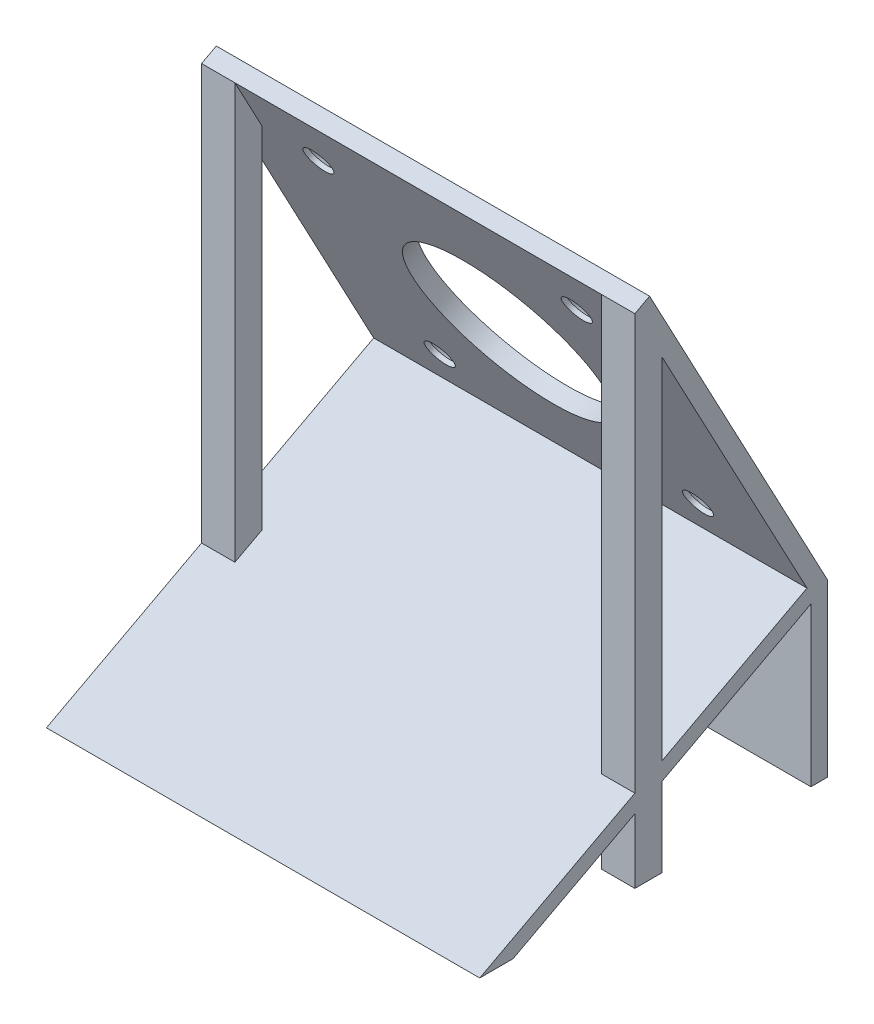
from build123d import *

# Parameters (mm, degrees)
SKETCH1_W                                           = 52
SKETCH1_H                                           = 100
BOSS_EXTRUDE1_DEPTH                                 = 5
BOSS_EXTRUDE3_DEPTH                                 = 2.5
SKETCH7_R                                           = 2.25
BOSS_EXTRUDE4_DEPTH                                 = 2.5
FILLET2_R                                           = 0.25
SKETCH9_W                                           = 52
SKETCH9_H                                           = 2
BOSS_EXTRUDE5_DEPTH                                 = 50
BOSS_EXTRUDE7_DEPTH                                 = 52
CUT_EXTRUDE3_DEPTH                                  = 52
CUT_EXTRUDE4_DEPTH                                  = 2.5
BOSS_EXTRUDE8_DEPTH                                 = 52
BOSS_EXTRUDE9_DEPTH                                 = 4
LPATTERN1_COUNT                                     = 2
LPATTERN1_PITCH                                     = 48
SKETCH18_R                                          = 11.5
CUT_EXTRUDE5_DEPTH                                  = 2
CSK_FOR_M3_COUNTERSUNK_FLAT_HEAD_SCREW1_D           = 3.4
CSK_FOR_M3_COUNTERSUNK_FLAT_HEAD_SCREW1_DEPTH       = 5
CSK_FOR_M3_COUNTERSUNK_FLAT_HEAD_SCREW1_CSINK_D     = 6.3
CSK_FOR_M3_COUNTERSUNK_FLAT_HEAD_SCREW1_CSINK_ANGLE = 90
CSK_FOR_M3_COUNTERSUNK_FLAT_HEAD_SCREW1_TIP         = 1.021463052
BOSS_EXTRUDE10_DEPTH                                = 5
SKETCH23_R                                          = 1.75
CUT_EXTRUDE6_DEPTH                                  = 5
SKETCH24_W                                          = 6.6
SKETCH24_H                                          = 5.6
CUT_EXTRUDE7_DEPTH                                  = 2.5
SKETCH25_W                                          = 75
SKETCH25_H                                          = 5
SKETCH25_W_2                                        = 28.673992526
SKETCH25_H_2                                        = 8.232083525
CUT_EXTRUDE8_DEPTH                                  = 88


with BuildPart() as part:
    # Sketch1 → Boss-Extrude1 (new body)
    with BuildSketch(Plane(origin=(0, 0, 0), x_dir=(1, 0, 0), z_dir=(0, 1, 0))):
        Rectangle(SKETCH1_W, SKETCH1_H)
    extrude(amount=BOSS_EXTRUDE1_DEPTH)

    # Sketch2 → Boss-Extrude3 (add)
    with BuildSketch(Plane(origin=(0, 5, 0), x_dir=(1, 0, 0), z_dir=(0, 1, 0))):
        with BuildLine():
            Line((-26, 50), (26, 50))
            Line((26, 50), (26, 30))
            ThreePointArc((26, 30), (0, 22.708313008), (-26, 30))
            Line((-26, 30), (-26, 50))
        make_face()
    extrude(amount=BOSS_EXTRUDE3_DEPTH)

    # Sketch7 → Boss-Extrude4 (add)
    with BuildSketch(Plane(origin=(0, 7.5, 0), x_dir=(1, 0, 0), z_dir=(0, 1, 0))):
        with Locations((-7.5, 40.5)):
            Circle(SKETCH7_R)
        with Locations((7.5, 40.5)):
            Circle(SKETCH7_R)
    extrude(amount=BOSS_EXTRUDE4_DEPTH)

    # Fillet2
    fillet2_edges = [part.edges().sort_by_distance(p)[0] for p in [
        (-9.75, 10, -40.5),
        (5.25, 10, -40.5),
    ]]
    fillet(fillet2_edges, radius=FILLET2_R)

    # Sketch9 → Boss-Extrude5 (add)
    with BuildSketch(Plane(origin=(0, 5, 0), x_dir=(1, 0, 0), z_dir=(0, 1, 0))):
        with Locations((0, -3)):
            Rectangle(SKETCH9_W, SKETCH9_H)
    extrude(amount=BOSS_EXTRUDE5_DEPTH)

    # Sketch10 → Boss-Extrude7 (add)
    with BuildSketch(Plane.ZY.offset(26)):
        Polygon((4, 25), (25.126220325, 64.732641679), (23.36032514, 65.671584804), (4, 29.260108936), align=None)
    extrude(amount=-BOSS_EXTRUDE7_DEPTH)

    # Sketch11 → Cut-Extrude3 (cut)
    with BuildSketch(Plane.ZY.offset(26)):
        Polygon((4, 29.260108936), (2, 25.498656006), (2, 55), (4, 55), align=None)
    extrude(amount=-CUT_EXTRUDE3_DEPTH, mode=Mode.SUBTRACT)

    # Sketch13 → Cut-Extrude4 (cut)
    with BuildSketch(Plane(origin=(0, 7.5, 0), x_dir=(1, 0, 0), z_dir=(0, 1, 0))):
        with BuildLine():
            Line((-14.75, 24.933450371), (-14.75, 50))
            Line((-14.75, 50), (-26, 50))
            Line((-26, 50), (-26, 30))
            ThreePointArc((-26, 30), (-20.531880242, 27.118381074), (-14.75, 24.933450371))
        make_face()
        with BuildLine():
            Line((26, 50), (14.75, 50))
            Line((14.75, 50), (14.75, 24.933450371))
            ThreePointArc((14.75, 24.933450371), (20.531880242, 27.118381074), (26, 30))
            Line((26, 30), (26, 50))
        make_face()
    extrude(amount=-CUT_EXTRUDE4_DEPTH, mode=Mode.SUBTRACT)

    # Sketch16 → Boss-Extrude8 (add)
    with BuildSketch(Plane.ZY.offset(26)):
        Polygon((4.469471563, 25.882947593), (43.744583775, 5), (39.744583775, 5), (4, 24.005732324), (4, 25), align=None)
    extrude(amount=-BOSS_EXTRUDE8_DEPTH)

    # Sketch17 → Boss-Extrude9 (add)
    with BuildSketch(Plane.ZY.offset(26)):
        Polygon((25.126220325, 64.732641679), (25.126220325, 5), (21.872291888, 5), (21.872291888, 58.612892349), align=None)
    boss_extrude9 = extrude(amount=-BOSS_EXTRUDE9_DEPTH)

    # LPattern1: Boss-Extrude9 ×2
    with Locations(*[(i * LPATTERN1_PITCH, 0, 0) for i in range(1, LPATTERN1_COUNT)]):
        add(boss_extrude9)

    # Sketch18 → Cut-Extrude5 (cut)
    with BuildSketch(Plane(origin=(0, 4.790956687, -9.010479036), x_dir=(-1, 0, 0), z_dir=(0, 0.469471563, -0.882947593))):
        with Locations((0, 45.951576073)):
            Circle(SKETCH18_R)
    extrude(amount=-CUT_EXTRUDE5_DEPTH, mode=Mode.SUBTRACT)

    # CSK for M3 Countersunk Flat Head Screw1
    with Locations(Plane(origin=(0, 4.790956687, -9.010479036), x_dir=(-1, 0, 0), z_dir=(0, 0.469471563, -0.882947593))):
        with Locations((-15.5, 61.45224807), (15.5, 61.45224807), (15.5, 30.45224807), (-15.5, 30.45224807)):
            CounterSinkHole(CSK_FOR_M3_COUNTERSUNK_FLAT_HEAD_SCREW1_D / 2, CSK_FOR_M3_COUNTERSUNK_FLAT_HEAD_SCREW1_CSINK_D / 2, depth=CSK_FOR_M3_COUNTERSUNK_FLAT_HEAD_SCREW1_DEPTH, counter_sink_angle=CSK_FOR_M3_COUNTERSUNK_FLAT_HEAD_SCREW1_CSINK_ANGLE)
            with Locations((0, 0, -(CSK_FOR_M3_COUNTERSUNK_FLAT_HEAD_SCREW1_DEPTH + CSK_FOR_M3_COUNTERSUNK_FLAT_HEAD_SCREW1_TIP / 2))):  # 118° drill point
                Cone(0, CSK_FOR_M3_COUNTERSUNK_FLAT_HEAD_SCREW1_D / 2, CSK_FOR_M3_COUNTERSUNK_FLAT_HEAD_SCREW1_TIP, mode=Mode.SUBTRACT)

    # Sketch22 → Boss-Extrude10 (add)
    with BuildSketch(Plane.XZ):
        Polygon((26, 75), (-61, 75), (-61, 0), (-26, 0), (-26, 50), (26, 50), align=None)
    extrude(amount=-BOSS_EXTRUDE10_DEPTH)

    # Sketch23 → Cut-Extrude6 (cut)
    with BuildSketch(Plane(origin=(0, 5, 0), x_dir=(1, 0, 0), z_dir=(0, 1, 0))):
        with Locations((-31.5, -5.5)):
            Circle(SKETCH23_R)
        with Locations((-55.5, -5.5)):
            Circle(SKETCH23_R)
        with Locations((-55.5, -69.5)):
            Circle(SKETCH23_R)
        with Locations((-31.5, -69.5)):
            Circle(SKETCH23_R)
    extrude(amount=-CUT_EXTRUDE6_DEPTH, mode=Mode.SUBTRACT)

    # Sketch24 → Cut-Extrude7 (cut)
    with BuildSketch(Plane.XZ):
        with Locations((-31.5, 69.5)):
            Rectangle(SKETCH24_W, SKETCH24_H)
        with Locations((-55.5, 69.5)):
            Rectangle(SKETCH24_W, SKETCH24_H)
        with Locations((-31.5, 5.5)):
            Rectangle(SKETCH24_W, SKETCH24_H)
        with Locations((-55.5, 5.5)):
            Rectangle(SKETCH24_W, SKETCH24_H)
    extrude(amount=-CUT_EXTRUDE7_DEPTH, mode=Mode.SUBTRACT)

    # Sketch25 → Cut-Extrude8 (cut, through all)
    with BuildSketch(Plane.ZY.offset(61)):
        Polygon((0, 0), (0, 5), (-21.326007474, 5), (-50, 5), (-50, 0), align=None)
        with Locations((37.5, 2.5)):
            Rectangle(SKETCH25_W, SKETCH25_H)
        with Locations((-35.663003737, 9.116041763)):
            Rectangle(SKETCH25_W_2, SKETCH25_H_2)
    extrude(amount=-CUT_EXTRUDE8_DEPTH, mode=Mode.SUBTRACT)


solid = part.part
